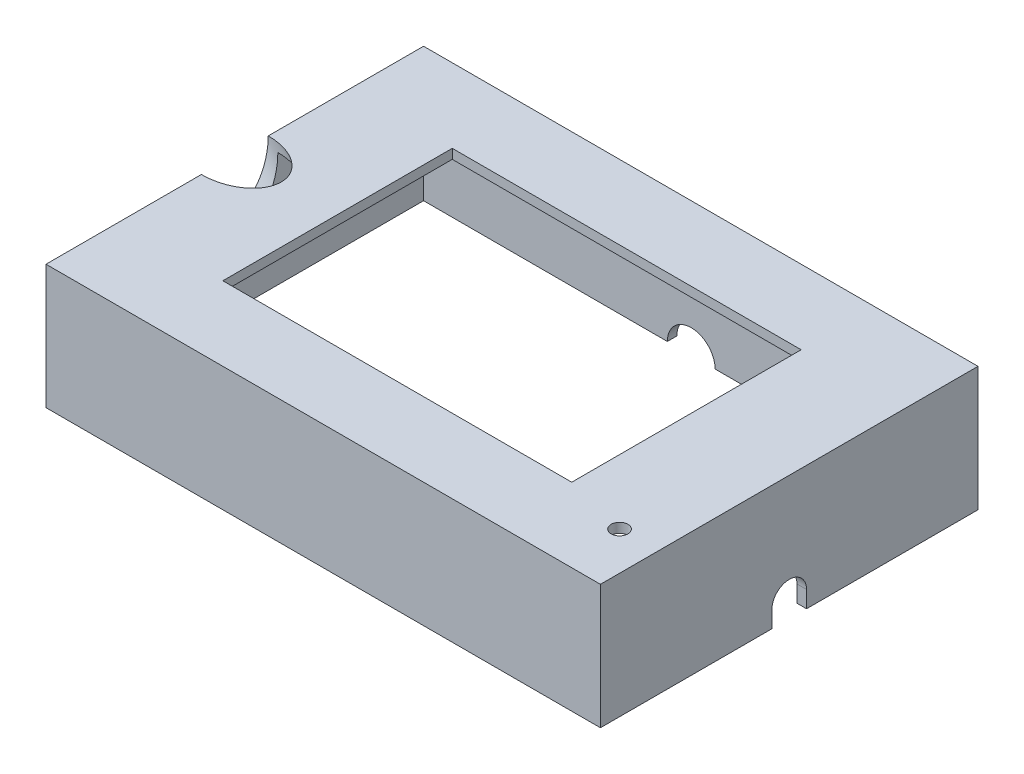
from build123d import *

# Parameters (mm, degrees)
SKETCH1_W           = 116
SKETCH1_H           = 79
SKETCH1_W_2         = 112
SKETCH1_H_2         = 75
BOSS_EXTRUDE1_DEPTH = 24
SKETCH2_W           = 116
SKETCH2_H           = 79
BOSS_EXTRUDE2_DEPTH = 2
SKETCH3_W           = 73
SKETCH3_H           = 48
CUT_EXTRUDE1_DEPTH  = 2
SKETCH4_R           = 1.75
CUT_EXTRUDE2_DEPTH  = 2
SKETCH6_R           = 7
CUT_EXTRUDE3_DEPTH  = 10
CUT_EXTRUDE4_DEPTH  = 2
SKETCH8_R           = 5
CUT_EXTRUDE5_DEPTH  = 2


with BuildPart() as part:
    # Sketch1 → Boss-Extrude1 (new body)
    with BuildSketch(Plane(origin=(0, 0, 0), x_dir=(1, 0, 0), z_dir=(0, 1, 0))):
        Rectangle(SKETCH1_W, SKETCH1_H)
        Rectangle(SKETCH1_W_2, SKETCH1_H_2, mode=Mode.SUBTRACT)
    extrude(amount=BOSS_EXTRUDE1_DEPTH)

    # Sketch2 → Boss-Extrude2 (add)
    with BuildSketch(Plane(origin=(0, 24, 0), x_dir=(1, 0, 0), z_dir=(0, 1, 0))):
        Rectangle(SKETCH2_W, SKETCH2_H)
    extrude(amount=BOSS_EXTRUDE2_DEPTH)

    # Sketch3 → Cut-Extrude1 (cut)
    with BuildSketch(Plane(origin=(0, 26, 0), x_dir=(1, 0, 0), z_dir=(0, 1, 0))):
        Rectangle(SKETCH3_W, SKETCH3_H)
    extrude(amount=-CUT_EXTRUDE1_DEPTH, mode=Mode.SUBTRACT)

    # Sketch4 → Cut-Extrude2 (cut)
    with BuildSketch(Plane(origin=(0, 26, 0), x_dir=(1, 0, 0), z_dir=(0, 1, 0))):
        with Locations((50, -27.5)):
            Circle(SKETCH4_R)
    extrude(amount=-CUT_EXTRUDE2_DEPTH, mode=Mode.SUBTRACT)

    # Sketch6 → Cut-Extrude3 (cut)
    with BuildSketch(Plane(origin=(-40.896797153, 42.46975089, 0), x_dir=(-0.720320213, -0.693641687, 0), z_dir=(0.693641687, -0.720320213, 0))):
        with Locations((23.743888519, 0)):
            Circle(SKETCH6_R)
    extrude(amount=CUT_EXTRUDE3_DEPTH, mode=Mode.SUBTRACT)

    # Sketch7 → Cut-Extrude4 (cut)
    with BuildSketch(Plane(origin=(58, 0, 0), x_dir=(0, 0, -1), z_dir=(1, 0, 0))):
        with BuildLine():
            Line((-3.625, 3.5), (-3.625, 0))
            Line((-3.625, 0), (3.625, 0))
            Line((3.625, 0), (3.625, 3.5))
            ThreePointArc((3.625, 3.5), (0, 7.125), (-3.625, 3.5))
        make_face()
    extrude(amount=-CUT_EXTRUDE4_DEPTH, mode=Mode.SUBTRACT)

    # Sketch8 → Cut-Extrude5 (cut)
    with BuildSketch(Plane(origin=(0, 0, -39.5), x_dir=(-1, 0, 0), z_dir=(0, 0, -1))):
        Circle(SKETCH8_R)
    extrude(amount=-CUT_EXTRUDE5_DEPTH, mode=Mode.SUBTRACT)


solid = part.part
